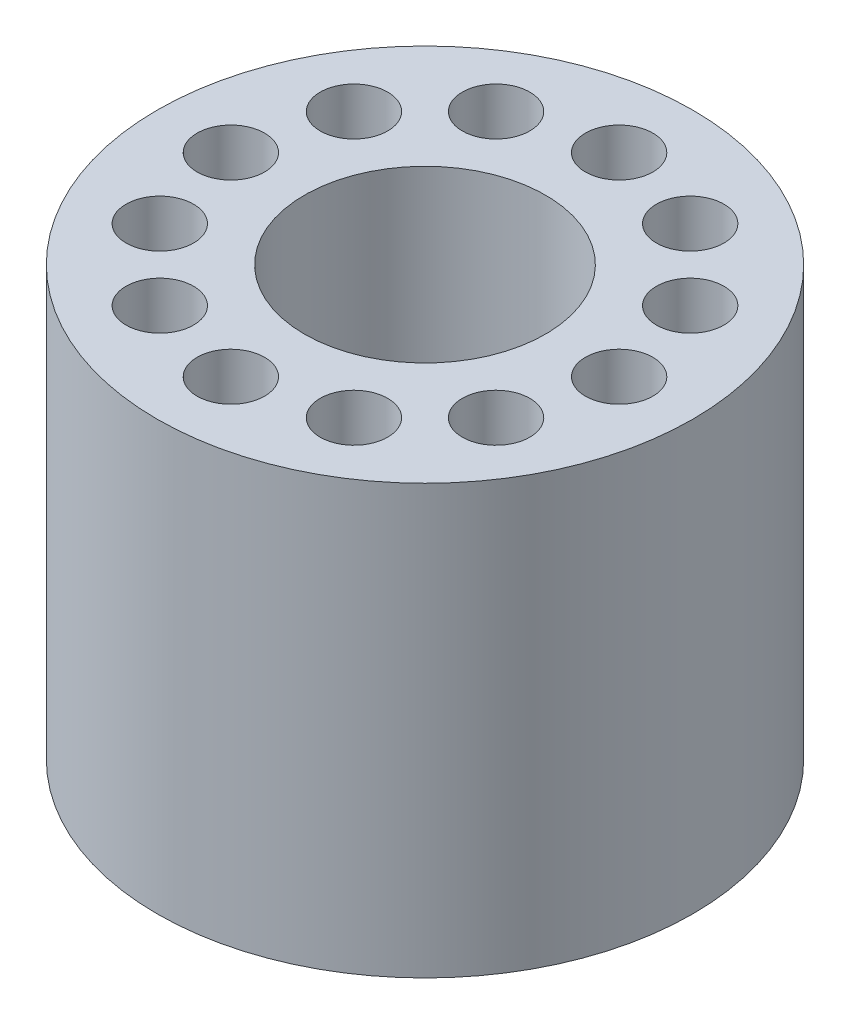
from build123d import *

# Parameters (mm, degrees)
SKETCH_1_R          = 15.875
SKETCH_1_R_2        = 7.14375
EXTRUDE_1_DEPTH     = 25.4
SKETCH_2_R          = 2
CUT_EXTRUDE_1_DEPTH = 25.4


with BuildPart() as part:
    # 스케치1 → 보스-돌출1 (new body)
    with BuildSketch(Plane(origin=(0, 0, 0), x_dir=(1, 0, 0), z_dir=(0, 1, 0))):
        Circle(SKETCH_1_R)
        Circle(SKETCH_1_R_2, mode=Mode.SUBTRACT)
    extrude(amount=EXTRUDE_1_DEPTH)

    # 스케치2 → 컷-돌출1 (cut)
    with BuildSketch(Plane(origin=(0, 25.4, 0), x_dir=(1, 0, 0), z_dir=(0, 1, 0))):
        with Locations((0, 11.509375)):
            Circle(SKETCH_2_R)
        with Locations((5.7546875, 9.967411132)):
            Circle(SKETCH_2_R)
        with Locations((9.967411132, 5.7546875)):
            Circle(SKETCH_2_R)
        with Locations((11.509375, 0)):
            Circle(SKETCH_2_R)
        with Locations((9.967411132, -5.7546875)):
            Circle(SKETCH_2_R)
        with Locations((5.7546875, -9.967411132)):
            Circle(SKETCH_2_R)
        with Locations((0, -11.509375)):
            Circle(SKETCH_2_R)
        with Locations((-5.7546875, -9.967411132)):
            Circle(SKETCH_2_R)
        with Locations((-9.967411132, -5.7546875)):
            Circle(SKETCH_2_R)
        with Locations((-11.509375, 0)):
            Circle(SKETCH_2_R)
        with Locations((-9.967411132, 5.7546875)):
            Circle(SKETCH_2_R)
        with Locations((-5.7546875, 9.967411132)):
            Circle(SKETCH_2_R)
    extrude(amount=-CUT_EXTRUDE_1_DEPTH, mode=Mode.SUBTRACT)


solid = part.part
